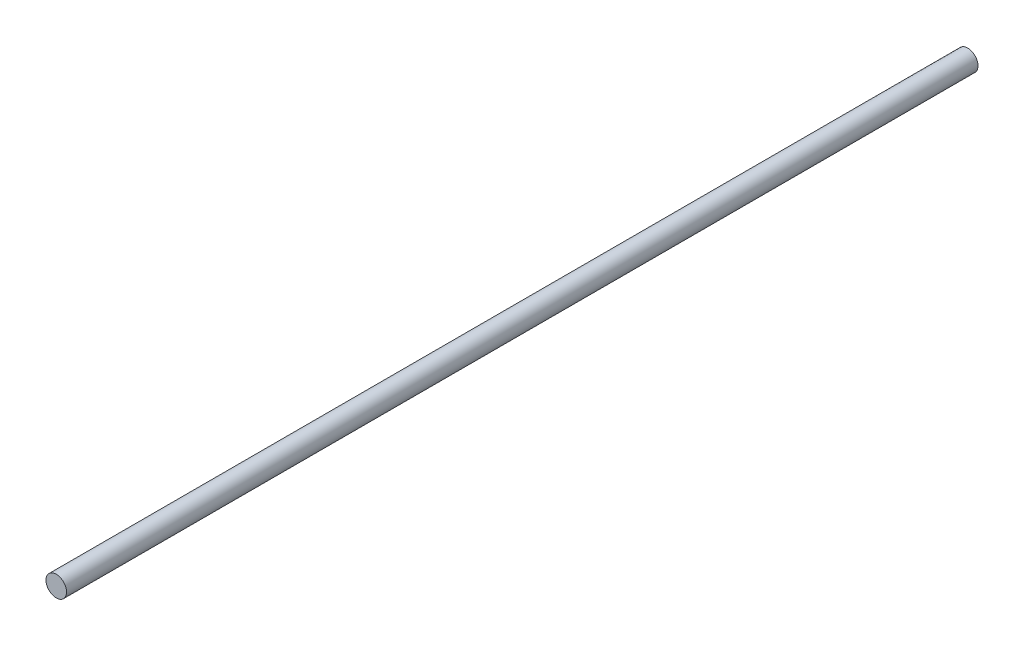
from build123d import *

# Parameters (mm, degrees)
IZIM1_R                     = 6
Y_KSEKLIK_EKSTR_ZYON1_DEPTH = 532


with BuildPart() as part:
    # Çizim1 → Yükseklik-Ekstrüzyon1 (new body)
    with BuildSketch(Plane.XY):
        Circle(IZIM1_R)
    extrude(amount=Y_KSEKLIK_EKSTR_ZYON1_DEPTH)


solid = part.part
